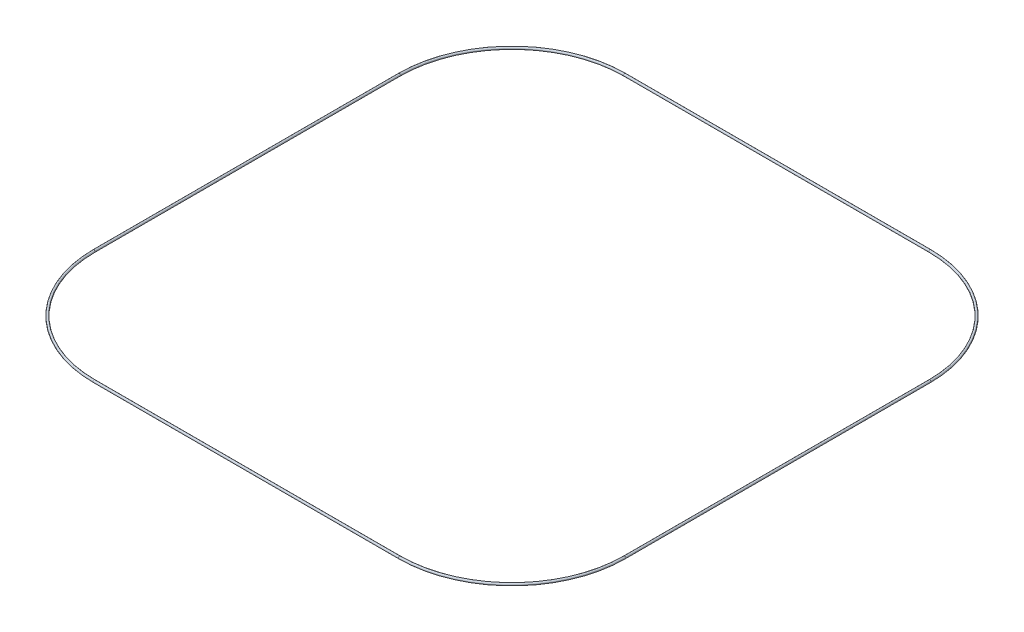
from build123d import *

# Parameters (mm, degrees)
SKETCH3_R = 1.5875


with BuildPart() as part:
    # Sweep2: sweep along a path in Sketch1
    with BuildLine(Plane(origin=(0, 0, 0), x_dir=(1, 0, 0), z_dir=(0, 1, 0))) as sweep2_path:
        Line((157.48, 0), (584.2, 0))
        ThreePointArc((584.2, 0), (695.555175901, 46.124824099), (741.68, 157.48))
        Line((741.68, 157.48), (741.68, 584.2))
        ThreePointArc((741.68, 584.2), (695.555175901, 695.555175901), (584.2, 741.68))
        Line((584.2, 741.68), (157.48, 741.68))
        ThreePointArc((157.48, 741.68), (46.124824099, 695.555175901), (0, 584.2))
        Line((0, 584.2), (0, 157.48))
        ThreePointArc((0, 157.48), (46.124824099, 46.124824099), (157.48, 0))
    # Sketch3 → Sweep2 (sweep)
    with BuildSketch(Plane(origin=(0, 0, -157.48), x_dir=(-1, 0, 0), z_dir=(0, 0, -1))):
        Circle(SKETCH3_R)
    sweep(path=sweep2_path.line)


solid = part.part
